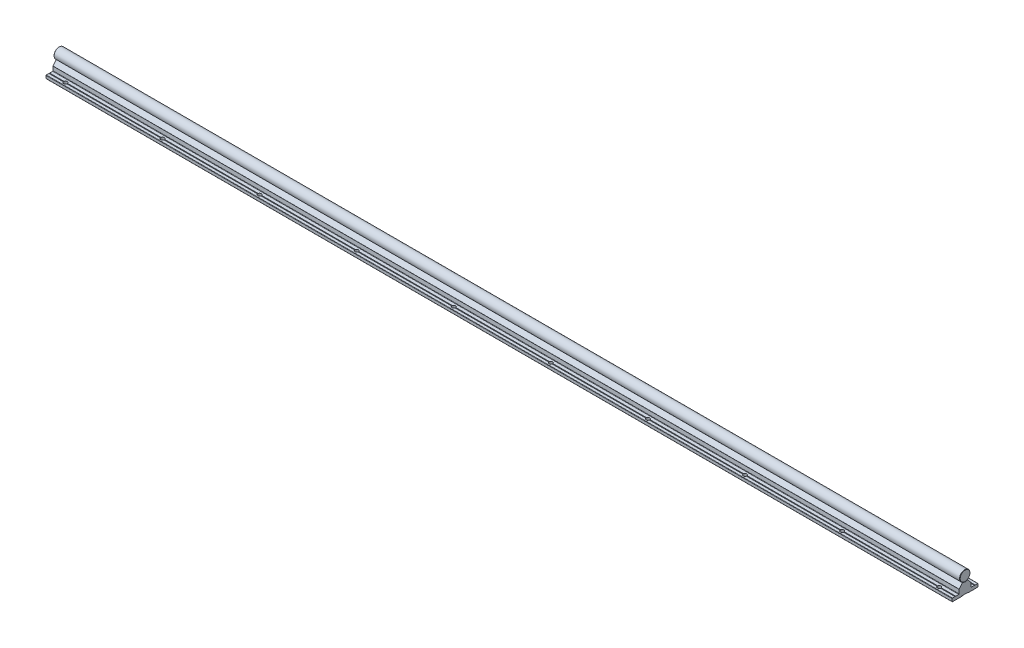
from build123d import *

# Parameters (mm, degrees)
EXTRUDE_6718_DEPTH       = 1500
SKETCH_1_3_R             = 8
EXTRUDE_6847_DEPTH       = 1500
FILLET_4_R               = 0.2
SKETCH_2_R               = 2.75
CUT_EXTRUDE_1_DEPTH      = 6
PATTERN_LINEAR_1_COUNT   = 20
PATTERN_LINEAR_1_PITCH   = 150
PATTERN_LINEAR_2_COUNT   = 20
PATTERN_LINEAR_2_PITCH   = 150
FILLET_1_R               = 0.3
CUT_EXTRUDE_2_DEPTH      = 3
FILLET_2_R               = 0.3
PATTERN_LINEAR_3_COUNT   = 20
PATTERN_LINEAR_3_PITCH   = 150
CHAMFER_1_SIZE           = 0.5
FILLET_3_R               = 0.5
FILLET_5_R               = 0.2
FILLET_6_R               = 0.1
FILLET_7_R               = 0.1
SKETCH_7_W               = 3500
SKETCH_7_H               = 1500
SKETCH_7_W_2             = 1400
SKETCH_7_H_2             = 1000
CUT_EXTRUDE_3_DEPTH      = 9.0000001
CUT_EXTRUDE_3_DEPTH_BACK = 26.0000001
CHAMFER_2_SIZE           = 0.5


with BuildPart() as part:
    # Sketch 1 → Extrude 6718 (new body, symmetric)
    with BuildSketch(Plane(origin=(0, 0, 0), x_dir=(0, 0, -1), z_dir=(1, 0, 0))):
        Polygon((-20, -25), (-4.75, -25), (-4.75, -24.4), (4.75, -24.4), (4.75, -25), (20, -25), (20, -20), (15.5, -20), (15, -20.5), (14.5, -20), (9.25, -20), (9.25, -13.3), (9.110116754, -13.3), (4, -7.21), (3.8, -7.21), (2.309327639, -7.659439004), (0, -8.355703281), (-2.309327657, -7.659438999), (-3.8, -7.21), (-4, -7.21), (-9.110116754, -13.3), (-9.25, -13.3), (-9.25, -20), (-14.5, -20), (-15, -20.5), (-15.5, -20), (-20, -20), align=None)
    extrude(amount=EXTRUDE_6718_DEPTH, both=True)

    # Fillet 4
    fillet_4_edges = [part.edges().sort_by_distance(p)[0] for p in [
        (0, -20, -15.5),
        (0, -24.4, -4.75),
        (0, -24.4, 4.75),
        (0, -20, 15.5),
        (0, -20, 14.5),
        (0, -8.355703281, 0),
        (0, -20, -14.5),
    ]]
    fillet(fillet_4_edges, radius=FILLET_4_R)

    # Sketch 2 → Cut-Extrude 1 (cut, through all)
    with BuildSketch(Plane(origin=(0, -20, 0), x_dir=(1, 0, 0), z_dir=(0, 1, 0))):
        with Locations((-1425, -15)):
            Circle(SKETCH_2_R)
        with Locations((-1425, 15)):
            Circle(SKETCH_2_R)
        with Locations((-1275, -15)):
            Circle(SKETCH_2_R)
        with Locations((-1275, 15)):
            Circle(SKETCH_2_R)
        with Locations((-1125, -15)):
            Circle(SKETCH_2_R)
        with Locations((-1125, 15)):
            Circle(SKETCH_2_R)
        with Locations((-975, -15)):
            Circle(SKETCH_2_R)
        with Locations((-975, 15)):
            Circle(SKETCH_2_R)
        with Locations((-825, -15)):
            Circle(SKETCH_2_R)
        with Locations((-825, 15)):
            Circle(SKETCH_2_R)
        with Locations((-675, -15)):
            Circle(SKETCH_2_R)
        with Locations((-675, 15)):
            Circle(SKETCH_2_R)
        with Locations((-525, -15)):
            Circle(SKETCH_2_R)
        with Locations((-525, 15)):
            Circle(SKETCH_2_R)
        with Locations((-375, -15)):
            Circle(SKETCH_2_R)
        with Locations((-375, 15)):
            Circle(SKETCH_2_R)
        with Locations((-225, -15)):
            Circle(SKETCH_2_R)
        with Locations((-225, 15)):
            Circle(SKETCH_2_R)
        with Locations((-75, -15)):
            Circle(SKETCH_2_R)
        with Locations((-75, 15)):
            Circle(SKETCH_2_R)
        with Locations((75, -15)):
            Circle(SKETCH_2_R)
        with Locations((75, 15)):
            Circle(SKETCH_2_R)
        with Locations((225, -15)):
            Circle(SKETCH_2_R)
        with Locations((225, 15)):
            Circle(SKETCH_2_R)
        with Locations((375, -15)):
            Circle(SKETCH_2_R)
        with Locations((375, 15)):
            Circle(SKETCH_2_R)
        with Locations((525, -15)):
            Circle(SKETCH_2_R)
        with Locations((525, 15)):
            Circle(SKETCH_2_R)
        with Locations((675, -15)):
            Circle(SKETCH_2_R)
        with Locations((675, 15)):
            Circle(SKETCH_2_R)
        with Locations((825, -15)):
            Circle(SKETCH_2_R)
        with Locations((825, 15)):
            Circle(SKETCH_2_R)
        with Locations((975, -15)):
            Circle(SKETCH_2_R)
        with Locations((975, 15)):
            Circle(SKETCH_2_R)
        with Locations((1125, -15)):
            Circle(SKETCH_2_R)
        with Locations((1125, 15)):
            Circle(SKETCH_2_R)
        with Locations((1275, -15)):
            Circle(SKETCH_2_R)
        with Locations((1275, 15)):
            Circle(SKETCH_2_R)
        with Locations((1425, -15)):
            Circle(SKETCH_2_R)
        with Locations((1425, 15)):
            Circle(SKETCH_2_R)
    extrude(amount=-CUT_EXTRUDE_1_DEPTH, mode=Mode.SUBTRACT)

    # Sketch 3 → Cut-Revolve 1 (revolve, cut)
    with BuildSketch(Plane.XY):
        Polygon((-1425, 0), (-1427.2, -1.270170592), (-1427.2, -7.5), (-1427.75, -7.5), (-1427.75, -19), (-1429.75, -19), (-1429.75, -24.4), (-1425, -24.4), align=None)
    cut_revolve_1 = revolve(axis=Axis((-1425, 56.434869358, 0), (0, -1, 0)), mode=Mode.SUBTRACT)

    # Pattern Linear 1: Cut-Revolve 1 ×20
    with Locations(*[(i * PATTERN_LINEAR_1_PITCH, 0, 0) for i in range(1, PATTERN_LINEAR_1_COUNT)]):
        add(cut_revolve_1, mode=Mode.SUBTRACT)

    # Fillet 3
    fillet_3_edges = [part.edges().sort_by_distance(p)[0] for p in [
        (0, -20, -9.25),
        (0, -20, -20),
        (0, -25, -20),
        (0, -25, -4.75),
        (0, -25, 4.75),
        (0, -20, 9.25),
        (0, -25, 20),
        (0, -20, 20),
    ]]
    fillet(fillet_3_edges, radius=FILLET_3_R)

    # Fillet 5
    fillet_5_edges = [part.edges().sort_by_distance(p)[0] for p in [
        (0, -7.21, 4),
        (0, -7.21, 3.8),
        (0, -7.21, -3.8),
        (0, -7.21, -4),
    ]]
    fillet(fillet_5_edges, radius=FILLET_5_R)

    # Fillet 6
    fillet_6_edges = [part.edges().sort_by_distance(p)[0] for p in [
        (0, -13.3, 9.25),
        (0, -13.3, -9.25),
    ]]
    fillet(fillet_6_edges, radius=FILLET_6_R)

    # Fillet 7
    fillet_7_edges = [part.edges().sort_by_distance(p)[0] for p in [
        (0, -13.3, 9.110116754),
        (0, -13.3, -9.110116754),
    ]]
    fillet(fillet_7_edges, radius=FILLET_7_R)


with BuildPart() as body_2:
    # Sketch 1_3 → Extrude 6847 (new body, symmetric)
    with BuildSketch(Plane(origin=(0, 0, 0), x_dir=(0, 0, -1), z_dir=(1, 0, 0))):
        Circle(SKETCH_1_3_R)
    extrude(amount=EXTRUDE_6847_DEPTH, both=True)

    # Sketch 4 → Cut-Revolve 2 (revolve, cut)
    with BuildSketch(Plane.XY):
        Polygon((-1425, -10), (-1427.2, -10), (-1427.2, -1.270170592), (-1425, 0), align=None)
    cut_revolve_2 = revolve(axis=Axis((-1425, 39.840222878, 0), (0, -1, 0)), mode=Mode.SUBTRACT)

    # Pattern Linear 2: Cut-Revolve 2 ×20
    with Locations(*[(i * PATTERN_LINEAR_2_PITCH, 0, 0) for i in range(1, PATTERN_LINEAR_2_COUNT)]):
        add(cut_revolve_2, mode=Mode.SUBTRACT)

    # Chamfer 1
    chamfer_1_edges = [body_2.edges().sort_by_distance(p)[0] for p in [
        (-1500, 0, 8),
        (1500, 0, 8),
    ]]
    chamfer(chamfer_1_edges, length=CHAMFER_1_SIZE)


with BuildPart() as body_3:
    # Sketch 5 → Revolve 1 (revolve)
    with BuildSketch(Plane.XY):
        Polygon((-1425, -24), (-1429.5, -24), (-1429.5, -19), (-1427.5, -19), (-1427.5, -2.461880215), (-1426.7, -2), (-1425, -2), align=None)
    revolve(axis=Axis((-1425, 35.529626596, 0), (0, -1, 0)))

    # Fillet 1
    fillet_1_edges = [body_3.edges().sort_by_distance(p)[0] for p in [
        (-1420.5, -19, 0),
    ]]
    fillet(fillet_1_edges, radius=FILLET_1_R)

    # Sketch 6 → Cut-Extrude 2 (cut)
    with BuildSketch(Plane.XZ.offset(24)):
        Polygon((-1423.25, -1.010362971), (-1423.25, 1.010362971), (-1425, 2.020725942), (-1426.75, 1.010362971), (-1426.75, -1.010362971), (-1425, -2.020725942), align=None)
    extrude(amount=-CUT_EXTRUDE_2_DEPTH, mode=Mode.SUBTRACT)

    # Fillet 2
    fillet_2_edges = [body_3.edges().sort_by_distance(p)[0] for p in [
        (-1424.125, -24, -1.515544457),
        (-1423.25, -24, 0),
        (-1424.125, -24, 1.515544457),
        (-1425.875, -24, 1.515544457),
        (-1426.75, -24, 0),
        (-1425.875, -24, -1.515544457),
        (-1420.5, -24, 0),
    ]]
    fillet(fillet_2_edges, radius=FILLET_2_R)


with BuildPart() as pattern_linear_3_1:
    # Pattern Linear 3: pattern copy
    add(body_3.part.moved(Location(Vector(1, 0, 0) * (1 * PATTERN_LINEAR_3_PITCH))))


with BuildPart() as pattern_linear_3_2:
    # Pattern Linear 3: pattern copy
    add(body_3.part.moved(Location(Vector(1, 0, 0) * (2 * PATTERN_LINEAR_3_PITCH))))


with BuildPart() as pattern_linear_3_3:
    # Pattern Linear 3: pattern copy
    add(body_3.part.moved(Location(Vector(1, 0, 0) * (3 * PATTERN_LINEAR_3_PITCH))))


with BuildPart() as pattern_linear_3_4:
    # Pattern Linear 3: pattern copy
    add(body_3.part.moved(Location(Vector(1, 0, 0) * (4 * PATTERN_LINEAR_3_PITCH))))


with BuildPart() as pattern_linear_3_5:
    # Pattern Linear 3: pattern copy
    add(body_3.part.moved(Location(Vector(1, 0, 0) * (5 * PATTERN_LINEAR_3_PITCH))))


with BuildPart() as pattern_linear_3_6:
    # Pattern Linear 3: pattern copy
    add(body_3.part.moved(Location(Vector(1, 0, 0) * (6 * PATTERN_LINEAR_3_PITCH))))


with BuildPart() as pattern_linear_3_7:
    # Pattern Linear 3: pattern copy
    add(body_3.part.moved(Location(Vector(1, 0, 0) * (7 * PATTERN_LINEAR_3_PITCH))))


with BuildPart() as pattern_linear_3_8:
    # Pattern Linear 3: pattern copy
    add(body_3.part.moved(Location(Vector(1, 0, 0) * (8 * PATTERN_LINEAR_3_PITCH))))


with BuildPart() as pattern_linear_3_9:
    # Pattern Linear 3: pattern copy
    add(body_3.part.moved(Location(Vector(1, 0, 0) * (9 * PATTERN_LINEAR_3_PITCH))))


with BuildPart() as pattern_linear_3_10:
    # Pattern Linear 3: pattern copy
    add(body_3.part.moved(Location(Vector(1, 0, 0) * (10 * PATTERN_LINEAR_3_PITCH))))


with BuildPart() as pattern_linear_3_11:
    # Pattern Linear 3: pattern copy
    add(body_3.part.moved(Location(Vector(1, 0, 0) * (11 * PATTERN_LINEAR_3_PITCH))))


with BuildPart() as pattern_linear_3_12:
    # Pattern Linear 3: pattern copy
    add(body_3.part.moved(Location(Vector(1, 0, 0) * (12 * PATTERN_LINEAR_3_PITCH))))


with BuildPart() as pattern_linear_3_13:
    # Pattern Linear 3: pattern copy
    add(body_3.part.moved(Location(Vector(1, 0, 0) * (13 * PATTERN_LINEAR_3_PITCH))))


with BuildPart() as pattern_linear_3_14:
    # Pattern Linear 3: pattern copy
    add(body_3.part.moved(Location(Vector(1, 0, 0) * (14 * PATTERN_LINEAR_3_PITCH))))


with BuildPart() as pattern_linear_3_15:
    # Pattern Linear 3: pattern copy
    add(body_3.part.moved(Location(Vector(1, 0, 0) * (15 * PATTERN_LINEAR_3_PITCH))))


with BuildPart() as pattern_linear_3_16:
    # Pattern Linear 3: pattern copy
    add(body_3.part.moved(Location(Vector(1, 0, 0) * (16 * PATTERN_LINEAR_3_PITCH))))


with BuildPart() as pattern_linear_3_17:
    # Pattern Linear 3: pattern copy
    add(body_3.part.moved(Location(Vector(1, 0, 0) * (17 * PATTERN_LINEAR_3_PITCH))))


with BuildPart() as pattern_linear_3_18:
    # Pattern Linear 3: pattern copy
    add(body_3.part.moved(Location(Vector(1, 0, 0) * (18 * PATTERN_LINEAR_3_PITCH))))


with BuildPart() as pattern_linear_3_19:
    # Pattern Linear 3: pattern copy
    add(body_3.part.moved(Location(Vector(1, 0, 0) * (19 * PATTERN_LINEAR_3_PITCH))))


with BuildPart() as cut_extrude_3_tool:
    # Sketch 7 → Cut-Extrude 3 (new body, two sides)
    with BuildSketch(Plane(origin=(0, 0, 0), x_dir=(1, 0, 0), z_dir=(0, 1, 0))) as cut_extrude_3_sk:
        Rectangle(SKETCH_7_W, SKETCH_7_H)
        Rectangle(SKETCH_7_W_2, SKETCH_7_H_2, mode=Mode.SUBTRACT)
    extrude(amount=CUT_EXTRUDE_3_DEPTH)
    extrude(cut_extrude_3_sk.sketch, amount=-CUT_EXTRUDE_3_DEPTH_BACK)


with BuildPart() as part_1:
    add(part.part)

    # Cut-Extrude 3: cut by cut_extrude_3_tool
    add(cut_extrude_3_tool.part, mode=Mode.SUBTRACT)


with BuildPart() as body_2_1:
    add(body_2.part)

    # Cut-Extrude 3: cut by cut_extrude_3_tool
    add(cut_extrude_3_tool.part, mode=Mode.SUBTRACT)

    # Chamfer 2
    chamfer_2_edges = [body_2_1.edges().sort_by_distance(p)[0] for p in [
        (-700, 0, 8),
        (700, 0, 8),
    ]]
    chamfer(chamfer_2_edges, length=CHAMFER_2_SIZE)


with BuildPart() as body_3_1:
    add(body_3.part)

    # Cut-Extrude 3: cut by cut_extrude_3_tool
    add(cut_extrude_3_tool.part, mode=Mode.SUBTRACT)


with BuildPart() as pattern_linear_3_1_1:
    add(pattern_linear_3_1.part)

    # Cut-Extrude 3: cut by cut_extrude_3_tool
    add(cut_extrude_3_tool.part, mode=Mode.SUBTRACT)


with BuildPart() as pattern_linear_3_2_1:
    add(pattern_linear_3_2.part)

    # Cut-Extrude 3: cut by cut_extrude_3_tool
    add(cut_extrude_3_tool.part, mode=Mode.SUBTRACT)


with BuildPart() as pattern_linear_3_3_1:
    add(pattern_linear_3_3.part)

    # Cut-Extrude 3: cut by cut_extrude_3_tool
    add(cut_extrude_3_tool.part, mode=Mode.SUBTRACT)


with BuildPart() as pattern_linear_3_4_1:
    add(pattern_linear_3_4.part)

    # Cut-Extrude 3: cut by cut_extrude_3_tool
    add(cut_extrude_3_tool.part, mode=Mode.SUBTRACT)


with BuildPart() as pattern_linear_3_15_1:
    add(pattern_linear_3_15.part)

    # Cut-Extrude 3: cut by cut_extrude_3_tool
    add(cut_extrude_3_tool.part, mode=Mode.SUBTRACT)


with BuildPart() as pattern_linear_3_16_1:
    add(pattern_linear_3_16.part)

    # Cut-Extrude 3: cut by cut_extrude_3_tool
    add(cut_extrude_3_tool.part, mode=Mode.SUBTRACT)


with BuildPart() as pattern_linear_3_17_1:
    add(pattern_linear_3_17.part)

    # Cut-Extrude 3: cut by cut_extrude_3_tool
    add(cut_extrude_3_tool.part, mode=Mode.SUBTRACT)


with BuildPart() as pattern_linear_3_18_1:
    add(pattern_linear_3_18.part)

    # Cut-Extrude 3: cut by cut_extrude_3_tool
    add(cut_extrude_3_tool.part, mode=Mode.SUBTRACT)


with BuildPart() as pattern_linear_3_19_1:
    add(pattern_linear_3_19.part)

    # Cut-Extrude 3: cut by cut_extrude_3_tool
    add(cut_extrude_3_tool.part, mode=Mode.SUBTRACT)


solid = Compound([pattern_linear_3_5.part, pattern_linear_3_6.part, pattern_linear_3_7.part, pattern_linear_3_8.part, pattern_linear_3_9.part, pattern_linear_3_10.part, pattern_linear_3_11.part, pattern_linear_3_12.part, pattern_linear_3_13.part, pattern_linear_3_14.part, part_1.part, body_2_1.part])
